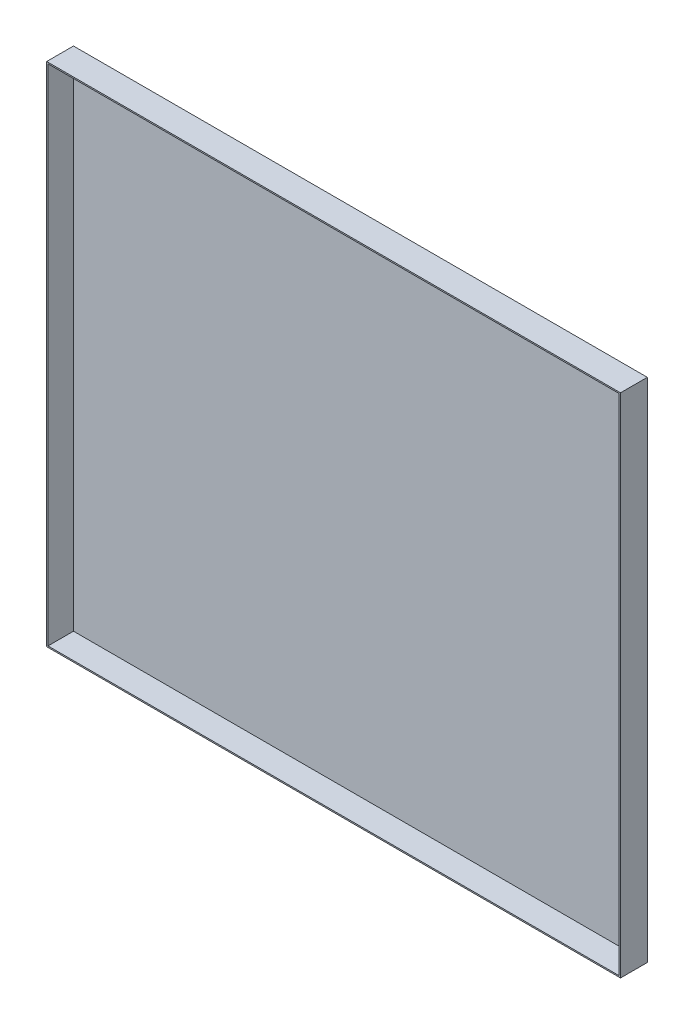
from build123d import *

# Parameters (mm, degrees)
SKETCH_1_W      = 428
SKETCH_1_H      = 378
EXTRUDE_1_DEPTH = 20
SHELL_1_T       = -1


with BuildPart() as part:
    # 草图1 → 凸台-拉伸1 (new body)
    with BuildSketch(Plane.XY):
        Rectangle(SKETCH_1_W, SKETCH_1_H)
    extrude(amount=EXTRUDE_1_DEPTH)

    # 抽壳1
    shell_1_openings = [part.faces().sort_by_distance(p)[0] for p in [
        (0, 0, 20),
    ]]
    offset(amount=SHELL_1_T, openings=shell_1_openings, kind=Kind.INTERSECTION)


solid = part.part
